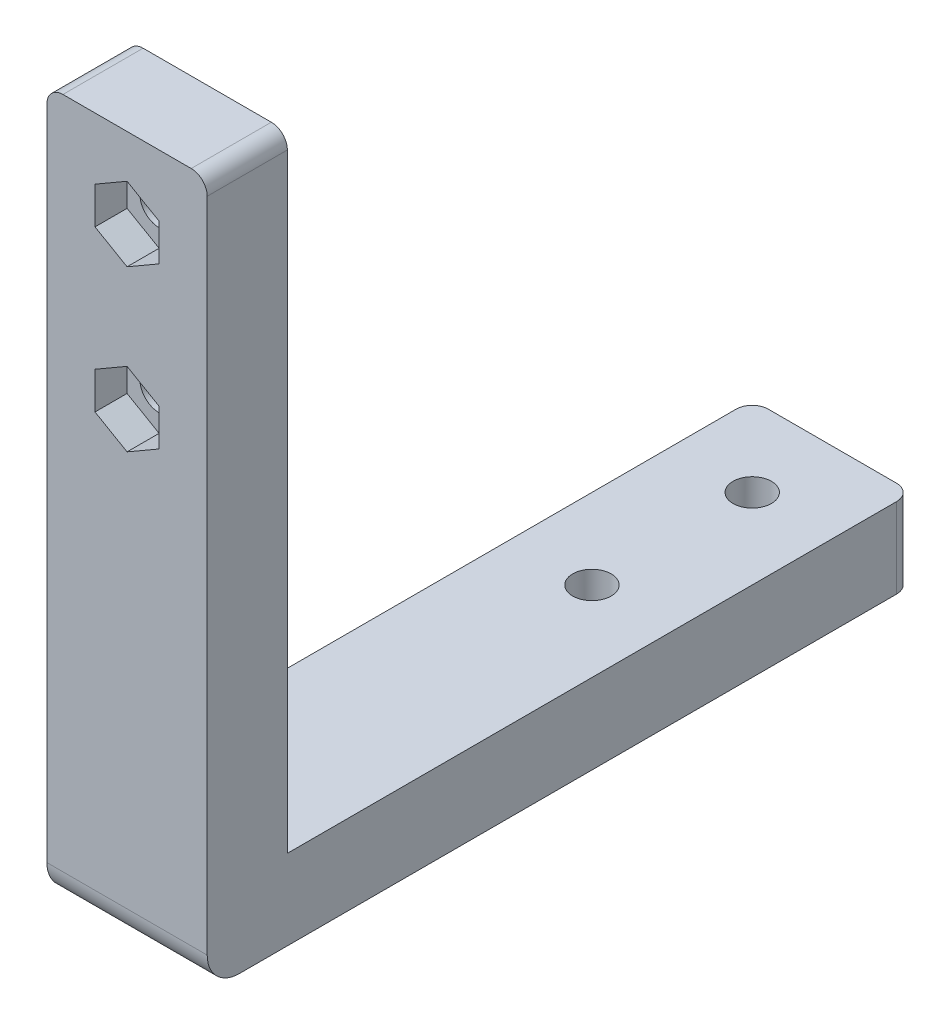
from build123d import *

# Parameters (mm, degrees)
EXTRUDE_1_DEPTH      = 5
EXTRUDE_1_DEPTH_BACK = 5
SKETCH_2_R           = 1.2
CUT_EXTRUDE_1_DEPTH  = 60.008473968
SKETCH_3_R           = 1.2
CUT_EXTRUDE_2_DEPTH  = 60.008473968
FILLET_1_R           = 1
FILLET_2_R           = 2
CUT_EXTRUDE1_DEPTH   = 2
CUT_EXTRUDE2_DEPTH   = 2


with BuildPart() as part:
    # Эскиз1 → Бобышка-Вытянуть1 (new, two sides: drawn at the far end of the back side and taken through both)
    with BuildSketch(Plane(origin=(0, 0, 0), x_dir=(0, 0, -1), z_dir=(1, 0, 0)).offset(-EXTRUDE_1_DEPTH_BACK)):
        Polygon((0, 44), (0, 0), (44, 0), (44, 5), (5, 5), (5, 44), align=None)
    extrude(amount=EXTRUDE_1_DEPTH + EXTRUDE_1_DEPTH_BACK)

    # Эскиз2 → Вырез-Вытянуть1 (cut, through all)
    with BuildSketch(Plane(origin=(0, 5, 0), x_dir=(1, 0, 0), z_dir=(0, 1, 0))):
        with Locations((0, 39)):
            Circle(SKETCH_2_R)
        with Locations((0, 29)):
            Circle(SKETCH_2_R)
    extrude(amount=-CUT_EXTRUDE_1_DEPTH, mode=Mode.SUBTRACT)

    # Эскиз3 → Вырез-Вытянуть2 (cut, through all)
    with BuildSketch(Plane(origin=(0, 0, -5), x_dir=(-1, 0, 0), z_dir=(0, 0, -1))):
        with Locations((0, 39)):
            Circle(SKETCH_3_R)
        with Locations((0, 29)):
            Circle(SKETCH_3_R)
    extrude(amount=-CUT_EXTRUDE_2_DEPTH, mode=Mode.SUBTRACT)

    # Скругление1
    fillet_1_edges = [part.edges().sort_by_distance(p)[0] for p in [
        (-5, 2.5, -44),
        (5, 2.5, -44),
        (5, 44, -2.5),
        (-5, 44, -2.5),
    ]]
    fillet(fillet_1_edges, radius=FILLET_1_R)

    # Скругление2
    fillet_2_edges = [part.edges().sort_by_distance(p)[0] for p in [
        (0, 0, 0),
    ]]
    fillet(fillet_2_edges, radius=FILLET_2_R)

    # Sketch1 → Cut-Extrude1 (cut)
    with BuildSketch(Plane(origin=(0, 0, 0), x_dir=(-1, 0, 0), z_dir=(0, 0, -1))):
        Polygon((2, 27.845299462), (0, 26.690598923), (-2, 27.845299462), (-2, 30.154700538), (0, 31.309401077), (2, 30.154700538), align=None)
        Polygon((0, 41.309401077), (-2, 40.154700538), (-2, 37.845299462), (0, 36.690598923), (2, 37.845299462), (2, 40.154700538), align=None)
    extrude(amount=CUT_EXTRUDE1_DEPTH, mode=Mode.SUBTRACT)

    # Sketch2 → Cut-Extrude2 (cut)
    with BuildSketch(Plane(origin=(0, 0, 0), x_dir=(1, 0, 0), z_dir=(0, 1, 0))):
        Polygon((2.309401077, 29), (1.154700538, 31), (-1.154700538, 31), (-2.309401077, 29), (-1.154700538, 27), (1.154700538, 27), align=None)
        Polygon((1.154700538, 41), (2.309401077, 39), (1.154700538, 37), (-1.154700538, 37), (-2.309401077, 39), (-1.154700538, 41), align=None)
    extrude(amount=CUT_EXTRUDE2_DEPTH, mode=Mode.SUBTRACT)


solid = part.part
